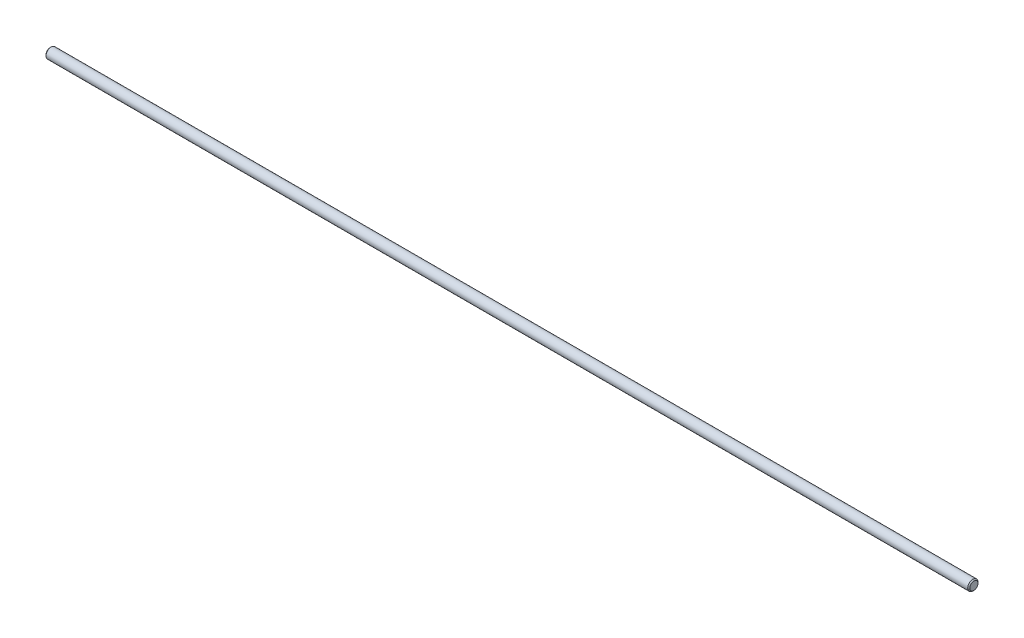
from build123d import *

# Parameters (mm, degrees)
SKETCH1_R           = 2.5
BOSS_EXTRUDE1_DEPTH = 450
CHAMFER1_SIZE       = 0.5


with BuildPart() as part:
    # Sketch1 → Boss-Extrude1 (new body)
    with BuildSketch(Plane(origin=(0, 0, 0), x_dir=(0, 0, -1), z_dir=(1, 0, 0))):
        Circle(SKETCH1_R)
    extrude(amount=BOSS_EXTRUDE1_DEPTH)

    # Chamfer1
    chamfer1_edges = [part.edges().sort_by_distance(p)[0] for p in [
        (0, 0, 2.5),
        (450, 0, 2.5),
    ]]
    chamfer(chamfer1_edges, length=CHAMFER1_SIZE)


solid = part.part
